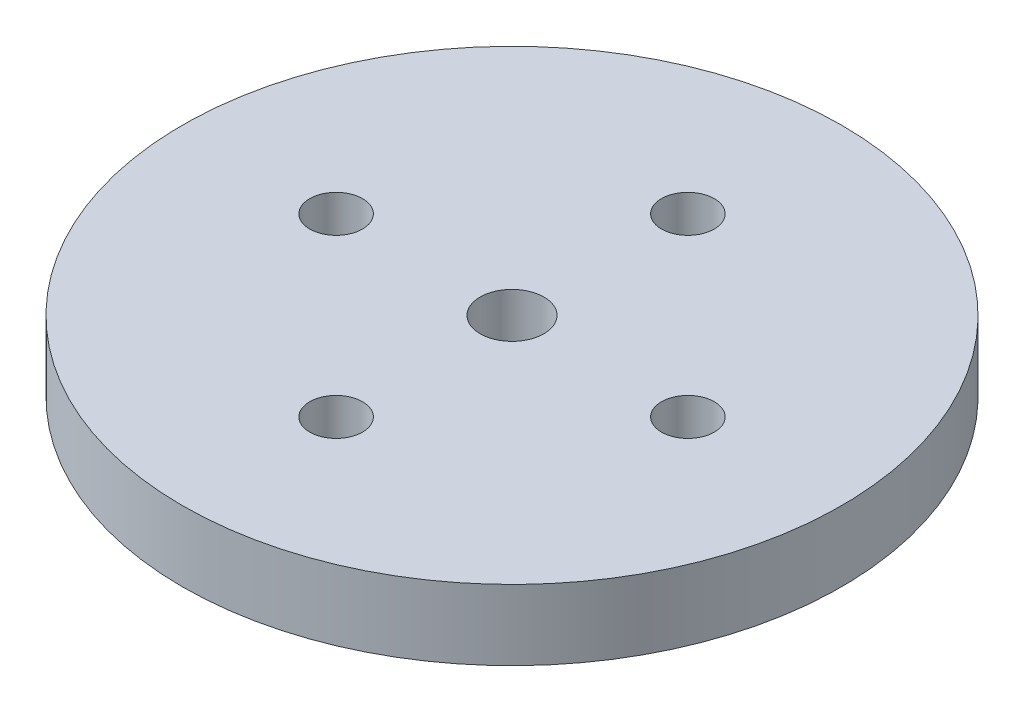
from build123d import *

# Parameters (mm, degrees)
SKETCH1_R           = 14.99
SKETCH1_R_2         = 1.45
SKETCH1_R_3         = 1.2
BOSS_EXTRUDE1_DEPTH = 3.2


with BuildPart() as part:
    # Sketch1 → Boss-Extrude1 (new body)
    with BuildSketch(Plane(origin=(0, 0, 0), x_dir=(1, 0, 0), z_dir=(0, 1, 0))):
        Circle(SKETCH1_R)
        Circle(SKETCH1_R_2, mode=Mode.SUBTRACT)
        with Locations((0, 8)):
            Circle(SKETCH1_R_3, mode=Mode.SUBTRACT)
        with Locations((8, 0)):
            Circle(SKETCH1_R_3, mode=Mode.SUBTRACT)
        with Locations((0, -8)):
            Circle(SKETCH1_R_3, mode=Mode.SUBTRACT)
        with Locations((-8, 0)):
            Circle(SKETCH1_R_3, mode=Mode.SUBTRACT)
    extrude(amount=BOSS_EXTRUDE1_DEPTH)


solid = part.part
